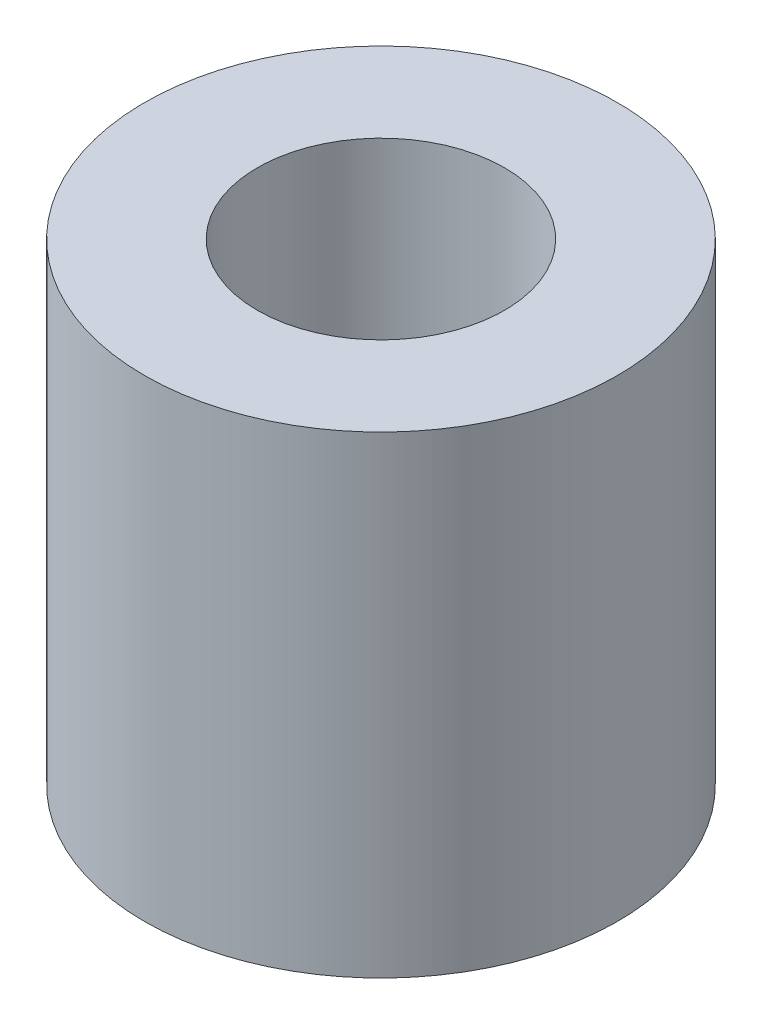
from build123d import *

# Parameters (mm, degrees)
SKETCH1_R           = 4.7625
SKETCH1_R_2         = 2.4892
BOSS_EXTRUDE1_DEPTH = 9.525


with BuildPart() as part:
    # Sketch1 → Boss-Extrude1 (new body)
    with BuildSketch(Plane(origin=(0, 0, 0), x_dir=(1, 0, 0), z_dir=(0, 1, 0))):
        Circle(SKETCH1_R)
        Circle(SKETCH1_R_2, mode=Mode.SUBTRACT)
    extrude(amount=BOSS_EXTRUDE1_DEPTH)


solid = part.part
